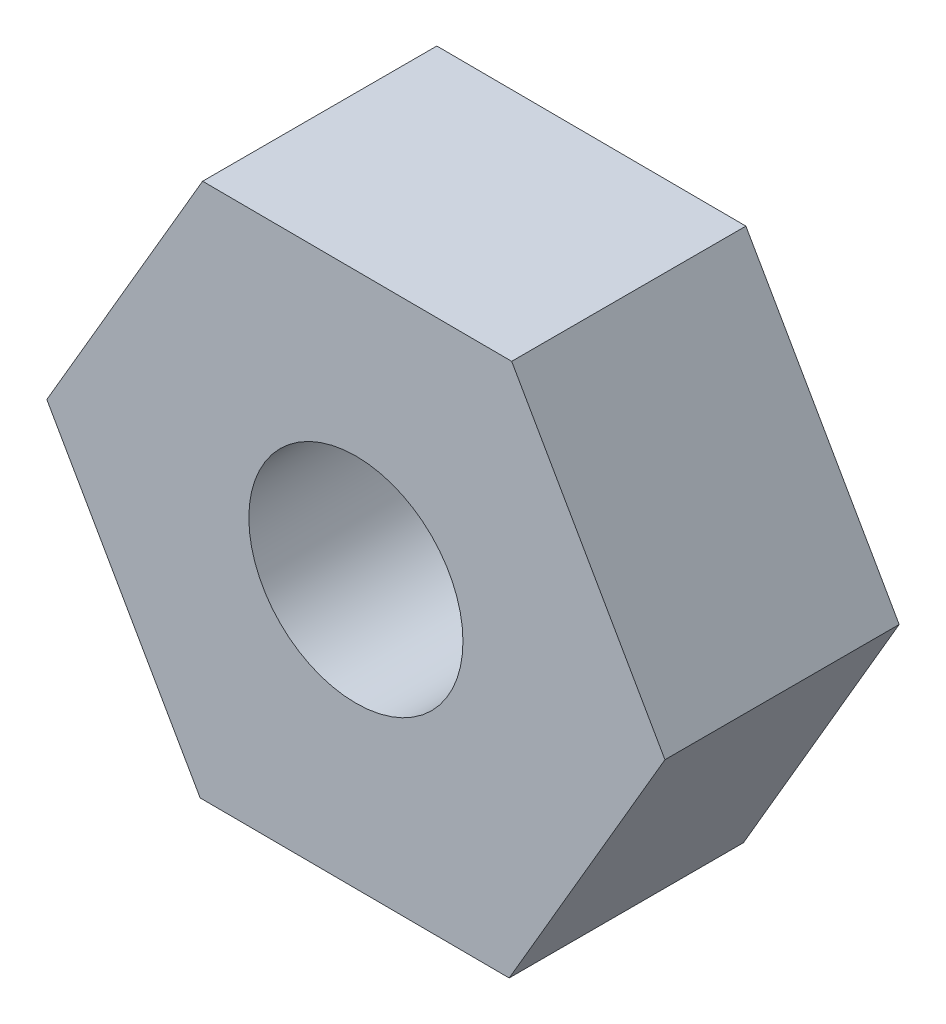
from build123d import *

# Parameters (mm, degrees)
SKETCH_1_R      = 1.6
EXTRUDE_1_DEPTH = 3.5


with BuildPart() as part:
    # 草图1 → 凸台-拉伸1 (new body)
    with BuildSketch(Plane.XY):
        Polygon((-2.290707001, 4.010734941), (-4.618751847, 0.021557015), (-2.328044846, -3.989177926), (2.290707001, -4.010734941), (4.618751847, -0.021557015), (2.328044846, 3.989177926), align=None)
        Circle(SKETCH_1_R, mode=Mode.SUBTRACT)
    extrude(amount=EXTRUDE_1_DEPTH)


solid = part.part
